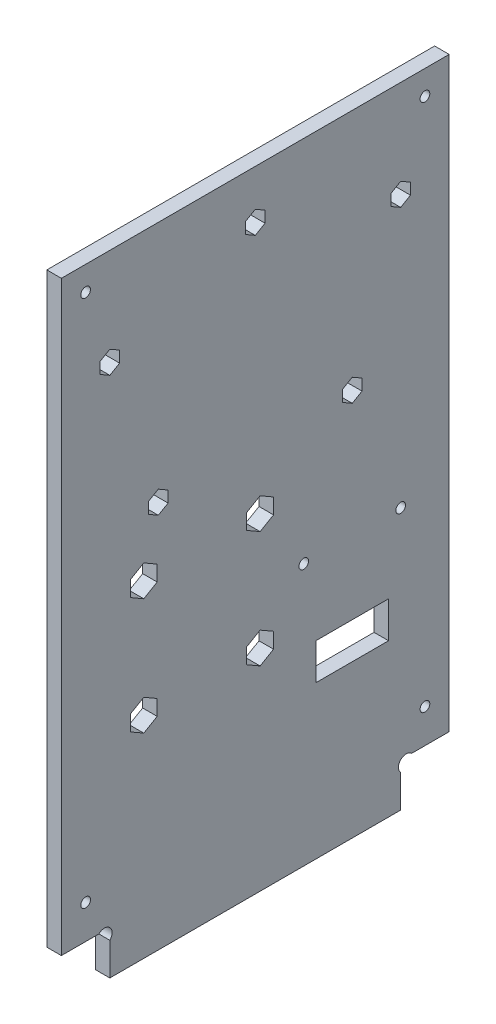
from build123d import *

# Parameters (mm, degrees)
EXTRUSION1_DEPTH        = 3
ESQUISSE2_R             = 1
ESQUISSE2_R_2           = 1.5
ENL_V_MAT_EXTRU_1_DEPTH = 4
ESQUISSE3_W             = 15
ESQUISSE3_H             = 7.5
ENL_V_MAT_EXTRU_2_DEPTH = 4
ESQUISSE4_R             = 1
ENL_V_MAT_EXTRU_3_DEPTH = 4
ENL_V_MAT_EXTRU_4_DEPTH = 4


with BuildPart() as part:
    # Esquisse1 → Extrusion1 (new body)
    with BuildSketch(Plane(origin=(0, 0, 0), x_dir=(0, 0, -1), z_dir=(1, 0, 0))):
        with BuildLine():
            Line((10, 6.7372583), (10, 0))
            Line((10, 0), (70, 0))
            Line((70, 0), (70, 6.7372583))
            ThreePointArc((70, 6.7372583), (70, 9), (72.2627417, 9))
            Line((72.2627417, 9), (80, 9))
            Line((80, 9), (80, 130))
            Line((80, 130), (0, 130))
            Line((0, 130), (0, 9))
            Line((0, 9), (7.7372583, 9))
            ThreePointArc((7.7372583, 9), (10, 9), (10, 6.7372583))
        make_face()
    extrude(amount=EXTRUSION1_DEPTH)

    # Esquisse2 → Enlèv. mat.-Extru.1 (cut, through all)
    with BuildSketch(Plane(origin=(3, 0, 0), x_dir=(0, 0, -1), z_dir=(1, 0, 0))):
        with Locations((60, 80)):
            Circle(ESQUISSE2_R)
        with Locations((10, 110)):
            Circle(ESQUISSE2_R)
        with Locations(Location((20, 80, 0), (0, 0, 180))):  # turned: the seam where the file's is
            Circle(ESQUISSE2_R)
        with Locations((70, 110)):
            Circle(ESQUISSE2_R)
        with Locations((17, 67.45)):
            Circle(ESQUISSE2_R_2)
        with Locations((17, 43.45)):
            Circle(ESQUISSE2_R_2)
        with Locations((41, 43.45)):
            Circle(ESQUISSE2_R_2)
        with Locations((41, 67.45)):
            Circle(ESQUISSE2_R_2)
        with Locations((40, 120)):
            Circle(ESQUISSE2_R)
        with Locations((70, 54)):
            Circle(ESQUISSE2_R)
        with Locations((50, 54)):
            Circle(ESQUISSE2_R)
    extrude(amount=-ENL_V_MAT_EXTRU_1_DEPTH, mode=Mode.SUBTRACT)

    # Esquisse3 → Enlèv. mat.-Extru.2 (cut, through all)
    with BuildSketch(Plane.ZY):
        with Locations((-60, 35.25)):
            Rectangle(ESQUISSE3_W, ESQUISSE3_H)
    extrude(amount=-ENL_V_MAT_EXTRU_2_DEPTH, mode=Mode.SUBTRACT)

    # Esquisse4 → Enlèv. mat.-Extru.3 (cut, through all)
    with BuildSketch(Plane(origin=(3, 0, 0), x_dir=(0, 0, -1), z_dir=(1, 0, 0))):
        with Locations((5, 125)):
            Circle(ESQUISSE4_R)
        with Locations((75, 125)):
            Circle(ESQUISSE4_R)
        with Locations((75, 16)):
            Circle(ESQUISSE4_R)
        with Locations((5, 16)):
            Circle(ESQUISSE4_R)
    extrude(amount=-ENL_V_MAT_EXTRU_3_DEPTH, mode=Mode.SUBTRACT)

    # Esquisse5 → Enlèv. mat.-Extru.4 (cut, through all)
    with BuildSketch(Plane(origin=(3, 0, 0), x_dir=(0, 0, -1), z_dir=(1, 0, 0))):
        Polygon((12.017839191, 111.165), (10, 112.33), (7.982160809, 111.165), (7.982160809, 108.835), (10, 107.67), (12.017839191, 108.835), align=None)
        Polygon((42.017839191, 118.835), (42.017839191, 121.165), (40, 122.33), (37.982160809, 121.165), (37.982160809, 118.835), (40, 117.67), align=None)
        Polygon((70, 107.67), (72.017839191, 108.835), (72.017839191, 111.165), (70, 112.33), (67.982160809, 111.165), (67.982160809, 108.835), align=None)
        Polygon((62.017839191, 78.835), (62.017839191, 81.165), (60, 82.33), (57.982160809, 81.165), (57.982160809, 78.835), (60, 77.67), align=None)
        Polygon((22.017839191, 78.835), (22.017839191, 81.165), (20, 82.33), (17.982160809, 81.165), (17.982160809, 78.835), (20, 77.67), align=None)
        Polygon((43.771281292, 65.85), (43.771281292, 69.05), (41, 70.65), (38.228718708, 69.05), (38.228718708, 65.85), (41, 64.25), align=None)
        Polygon((43.771281292, 41.85), (43.771281292, 45.05), (41, 46.65), (38.228718708, 45.05), (38.228718708, 41.85), (41, 40.25), align=None)
        Polygon((19.771281292, 41.85), (19.771281292, 45.05), (17, 46.65), (14.228718708, 45.05), (14.228718708, 41.85), (17, 40.25), align=None)
        Polygon((19.771281292, 65.85), (19.771281292, 69.05), (17, 70.65), (14.228718708, 69.05), (14.228718708, 65.85), (17, 64.25), align=None)
    extrude(amount=-ENL_V_MAT_EXTRU_4_DEPTH, mode=Mode.SUBTRACT)


solid = part.part
